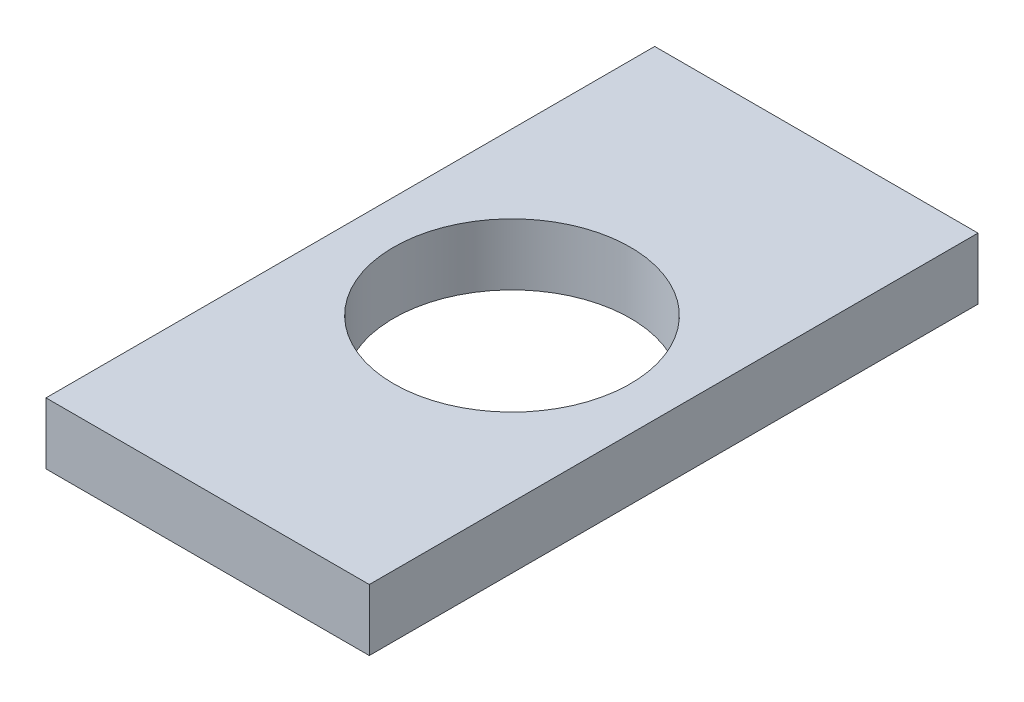
from build123d import *

# Parameters (mm, degrees)
SKETCH1_W           = 47.8
SKETCH1_H           = 90
SKETCH1_R           = 17.5
BOSS_EXTRUDE1_DEPTH = 9.1


with BuildPart() as part:
    # Sketch1 → Boss-Extrude1 (new body)
    with BuildSketch(Plane(origin=(0, 0, 0), x_dir=(1, 0, 0), z_dir=(0, 1, 0))):
        with Locations((23.9, 45)):
            Rectangle(SKETCH1_W, SKETCH1_H)
        with Locations((23.9, 45)):
            Circle(SKETCH1_R, mode=Mode.SUBTRACT)
    extrude(amount=BOSS_EXTRUDE1_DEPTH)


solid = part.part
